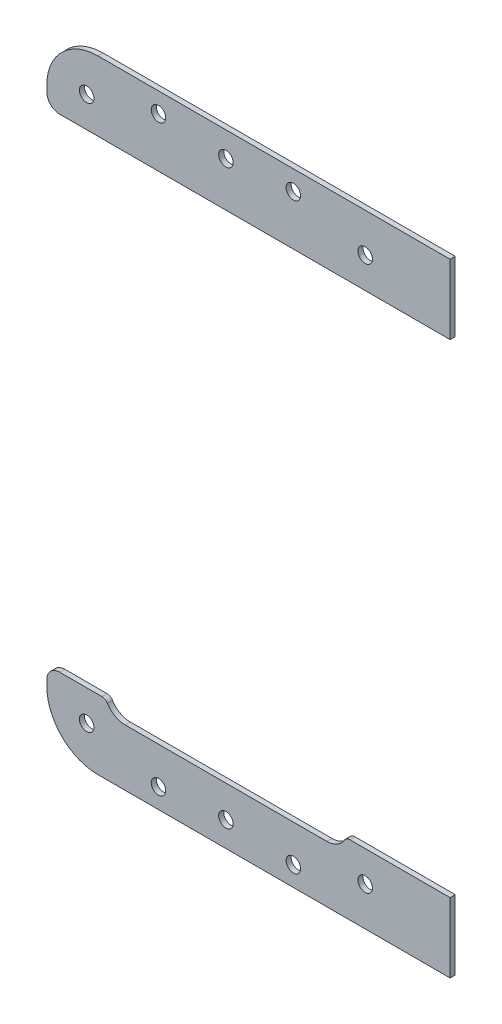
from build123d import *

# Parameters (mm, degrees)
SKETCH2_W                     = 111.125
SKETCH2_H                     = 193.04
BOSS_EXTRUDE1_DEPTH           = 1.5875
FILLET1_R                     = 15.875
SKETCH6_R                     = 2.4003
SKETCH6_R_2                   = 3
SKETCH6_R_3                   = 6.477
SKETCH6_R_4                   = 10.762
CUT_EXTRUDE1_DEPTH            = 212.192646736
SKETCH7_W                     = 13.97
SKETCH7_H                     = 193.04
BOSS_EXTRUDE2_DEPTH           = 1.5875
SKETCH8_W                     = 75.32443897
SKETCH8_H                     = 38.1
SKETCH8_R                     = 10.762
SKETCH8_R_2                   = 3
SKETCH8_H_2                   = 31.75
SKETCH8_H_3                   = 34.487219484
SKETCH8_R_3                   = 2.4003
SKETCH8_R_4                   = 6.477
SKETCH8_R_5                   = 8.9535
CUT_EXTRUDE2_DEPTH            = 1.5875
FILLET2_R                     = 9.525
FILLET3_R                     = 6.35
FILLET4_R                     = 9.525
SKETCH9_W                     = 125.095
SKETCH9_H                     = 149.86
CUT_EXTRUDE5_DEPTH            = 80
FILLET6_R                     = 4
FILLET8_R                     = 2
FILLET9_R                     = 2
FILLET10_R                    = 4
SKETCH4_W                     = 2.25
SKETCH4_H                     = 1.5875
M4_CLEARANCE_HOLE1_AT_2_COUNT = 2
M4_CLEARANCE_HOLE1_AT_2_PITCH = 43.406709572
M4_CLEARANCE_HOLE1_AT_3_COUNT = 2
M4_CLEARANCE_HOLE1_AT_3_PITCH = 86.3827405
M4_CLEARANCE_HOLE1_AT_4_COUNT = 2
M4_CLEARANCE_HOLE1_AT_4_PITCH = 189.737314909
M4_CLEARANCE_HOLE1_AT_5_COUNT = 2
M4_CLEARANCE_HOLE1_AT_5_PITCH = 178.553711266
M4_CLEARANCE_HOLE1_AT_6_COUNT = 2
M4_CLEARANCE_HOLE1_AT_6_PITCH = 168.9327405
M4_CLEARANCE_HOLE1_AT_7_COUNT = 2
M4_CLEARANCE_HOLE1_AT_7_PITCH = 23.050611575
M4_CLEARANCE_HOLE1_AT_8_COUNT = 2
M4_CLEARANCE_HOLE1_AT_8_PITCH = 186.221930585
SKETCH12_R                    = 2.25
CUT_EXTRUDE6_DEPTH            = 212.39048994


with BuildPart() as part:
    # Sketch2 → Boss-Extrude1 (new body)
    with BuildSketch(Plane.XY.offset(-401.504104662)):
        with Locations((-6.650833159, 105.295051609)):
            Rectangle(SKETCH2_W, SKETCH2_H)
        with BuildLine():
            ThreePointArc((40.429624387, 185.872334563), (40.429624387, 193.650509156), (32.651449794, 193.650509156))
            Line((32.651449794, 193.650509156), (29.670992248, 190.670051609))
            Line((29.670992248, 190.670051609), (-1.150833159, 190.670051609))
            Line((-1.150833159, 190.670051609), (-1.150833159, 194.079751609))
            ThreePointArc((-1.150833159, 194.079751609), (-6.650833159, 199.579751609), (-12.150833159, 194.079751609))
            Line((-12.150833159, 194.079751609), (-12.150833159, 190.670051609))
            Line((-12.150833159, 190.670051609), (-42.972658566, 190.670051609))
            Line((-42.972658566, 190.670051609), (-45.953116112, 193.650509156))
            ThreePointArc((-45.953116112, 193.650509156), (-53.731290705, 193.650509156), (-53.731290705, 185.872334563))
            Line((-53.731290705, 185.872334563), (-50.750833159, 182.891877016))
            Line((-50.750833159, 182.891877016), (-50.750833159, 138.989051609))
            Line((-50.750833159, 138.989051609), (-54.160533159, 138.989051609))
            ThreePointArc((-54.160533159, 138.989051609), (-59.660533159, 133.489051609), (-54.160533159, 127.989051609))
            Line((-54.160533159, 127.989051609), (-50.750833159, 127.989051609))
            Line((-50.750833159, 127.989051609), (-50.750833159, 82.601051609))
            Line((-50.750833159, 82.601051609), (-54.160533159, 82.601051609))
            ThreePointArc((-54.160533159, 82.601051609), (-59.660533159, 77.101051609), (-54.160533159, 71.601051609))
            Line((-54.160533159, 71.601051609), (-50.750833159, 71.601051609))
            Line((-50.750833159, 71.601051609), (-50.750833159, 27.698226203))
            Line((-50.750833159, 27.698226203), (-53.731290705, 24.717768656))
            ThreePointArc((-53.731290705, 24.717768656), (-53.731290705, 16.939594063), (-45.953116112, 16.939594063))
            Line((-45.953116112, 16.939594063), (-42.972658566, 19.920051609))
            Line((-42.972658566, 19.920051609), (-12.150833159, 19.920051609))
            Line((-12.150833159, 19.920051609), (-12.150833159, 16.510351609))
            ThreePointArc((-12.150833159, 16.510351609), (-6.650833159, 11.010351609), (-1.150833159, 16.510351609))
            Line((-1.150833159, 16.510351609), (-1.150833159, 19.920051609))
            Line((-1.150833159, 19.920051609), (29.670992248, 19.920051609))
            Line((29.670992248, 19.920051609), (32.651449794, 16.939594063))
            ThreePointArc((32.651449794, 16.939594063), (40.429624387, 16.939594063), (40.429624387, 24.717768656))
            Line((40.429624387, 24.717768656), (37.449166841, 27.698226203))
            Line((37.449166841, 27.698226203), (37.449166841, 71.601051609))
            Line((37.449166841, 71.601051609), (40.858866841, 71.601051609))
            ThreePointArc((40.858866841, 71.601051609), (46.358866841, 77.101051609), (40.858866841, 82.601051609))
            Line((40.858866841, 82.601051609), (37.449166841, 82.601051609))
            Line((37.449166841, 82.601051609), (37.449166841, 127.989051609))
            Line((37.449166841, 127.989051609), (40.858866841, 127.989051609))
            ThreePointArc((40.858866841, 127.989051609), (46.358866841, 133.489051609), (40.858866841, 138.989051609))
            Line((40.858866841, 138.989051609), (37.449166841, 138.989051609))
            Line((37.449166841, 138.989051609), (37.449166841, 182.891877016))
            Line((37.449166841, 182.891877016), (40.429624387, 185.872334563))
        make_face(mode=Mode.SUBTRACT)
        with BuildLine():
            Line((37.449166841, 182.891877016), (40.429624387, 185.872334563))
            ThreePointArc((40.429624387, 185.872334563), (40.429624387, 193.650509156), (32.651449794, 193.650509156))
            Line((32.651449794, 193.650509156), (29.670992248, 190.670051609))
            Line((29.670992248, 190.670051609), (-1.150833159, 190.670051609))
            Line((-1.150833159, 190.670051609), (-1.150833159, 194.079751609))
            ThreePointArc((-1.150833159, 194.079751609), (-6.650833159, 199.579751609), (-12.150833159, 194.079751609))
            Line((-12.150833159, 194.079751609), (-12.150833159, 190.670051609))
            Line((-12.150833159, 190.670051609), (-42.972658566, 190.670051609))
            Line((-42.972658566, 190.670051609), (-45.953116112, 193.650509156))
            ThreePointArc((-45.953116112, 193.650509156), (-53.731290705, 193.650509156), (-53.731290705, 185.872334563))
            Line((-53.731290705, 185.872334563), (-50.750833159, 182.891877016))
            Line((-50.750833159, 182.891877016), (-50.750833159, 138.989051609))
            Line((-50.750833159, 138.989051609), (-54.160533159, 138.989051609))
            ThreePointArc((-54.160533159, 138.989051609), (-59.660533159, 133.489051609), (-54.160533159, 127.989051609))
            Line((-54.160533159, 127.989051609), (-50.750833159, 127.989051609))
            Line((-50.750833159, 127.989051609), (-50.750833159, 82.601051609))
            Line((-50.750833159, 82.601051609), (-54.160533159, 82.601051609))
            ThreePointArc((-54.160533159, 82.601051609), (-59.660533159, 77.101051609), (-54.160533159, 71.601051609))
            Line((-54.160533159, 71.601051609), (-50.750833159, 71.601051609))
            Line((-50.750833159, 71.601051609), (-50.750833159, 27.698226203))
            Line((-50.750833159, 27.698226203), (-53.731290705, 24.717768656))
            ThreePointArc((-53.731290705, 24.717768656), (-53.731290705, 16.939594063), (-45.953116112, 16.939594063))
            Line((-45.953116112, 16.939594063), (-42.972658566, 19.920051609))
            Line((-42.972658566, 19.920051609), (-12.150833159, 19.920051609))
            Line((-12.150833159, 19.920051609), (-12.150833159, 16.510351609))
            ThreePointArc((-12.150833159, 16.510351609), (-6.650833159, 11.010351609), (-1.150833159, 16.510351609))
            Line((-1.150833159, 16.510351609), (-1.150833159, 19.920051609))
            Line((-1.150833159, 19.920051609), (29.670992248, 19.920051609))
            Line((29.670992248, 19.920051609), (32.651449794, 16.939594063))
            ThreePointArc((32.651449794, 16.939594063), (40.429624387, 16.939594063), (40.429624387, 24.717768656))
            Line((40.429624387, 24.717768656), (37.449166841, 27.698226203))
            Line((37.449166841, 27.698226203), (37.449166841, 71.601051609))
            Line((37.449166841, 71.601051609), (40.858866841, 71.601051609))
            ThreePointArc((40.858866841, 71.601051609), (46.358866841, 77.101051609), (40.858866841, 82.601051609))
            Line((40.858866841, 82.601051609), (37.449166841, 82.601051609))
            Line((37.449166841, 82.601051609), (37.449166841, 127.989051609))
            Line((37.449166841, 127.989051609), (40.858866841, 127.989051609))
            ThreePointArc((40.858866841, 127.989051609), (46.358866841, 133.489051609), (40.858866841, 138.989051609))
            Line((40.858866841, 138.989051609), (37.449166841, 138.989051609))
            Line((37.449166841, 138.989051609), (37.449166841, 182.891877016))
        make_face()
    extrude(amount=BOSS_EXTRUDE1_DEPTH)

    # Fillet1
    fillet1_edges = [part.edges().sort_by_distance(p)[0] for p in [
        (-62.213333159, 201.815051609, -400.710354662),
        (-62.213333159, 8.775051609, -400.710354662),
    ]]
    fillet(fillet1_edges, radius=FILLET1_R)

    # Sketch6 → Cut-Extrude1 (cut, through all)
    with BuildSketch(Plane.XY.offset(-399.916604662)):
        with Locations((-34.590833159, 43.382551609)):
            Circle(SKETCH6_R)
        with Locations((21.289166841, 43.382551609)):
            Circle(SKETCH6_R)
        with Locations((-20.884724927, 142.590766631)):
            Circle(SKETCH6_R_2)
        with Locations((7.583058609, 166.225175879)):
            Circle(SKETCH6_R_2)
        with Locations((3.509166841, 43.382551609)):
            Circle(SKETCH6_R_3)
        with Locations((-16.810833159, 43.382551609)):
            Circle(SKETCH6_R_3)
        with Locations((-33.320833159, 123.670051609)):
            Circle(SKETCH6_R_3)
        with Locations((-6.650833159, 154.407971255)):
            Circle(SKETCH6_R_4)
        with Locations((-6.650833159, 94.607131964)):
            Circle(SKETCH6_R_4)
    extrude(amount=-CUT_EXTRUDE1_DEPTH, mode=Mode.SUBTRACT)

    # Sketch7 → Boss-Extrude2 (add)
    with BuildSketch(Plane.XY.offset(-399.916604662)):
        with Locations((55.896666841, 105.295051609)):
            Rectangle(SKETCH7_W, SKETCH7_H)
    extrude(amount=-BOSS_EXTRUDE2_DEPTH)

    # Sketch8 → Cut-Extrude2 (cut)
    with BuildSketch(Plane.XY.offset(-399.916604662)):
        with Locations((-6.650833159, 154.407971255)):
            Rectangle(SKETCH8_W, SKETCH8_H)
        with Locations((-6.650833159, 154.407971255)):
            Circle(SKETCH8_R, mode=Mode.SUBTRACT)
        with Locations((7.583058609, 166.225175879)):
            Circle(SKETCH8_R_2, mode=Mode.SUBTRACT)
        with Locations((-20.884724927, 142.590766631)):
            Circle(SKETCH8_R_2, mode=Mode.SUBTRACT)
        with Locations((-6.650833159, 94.607131964)):
            Rectangle(SKETCH8_W, SKETCH8_H_2)
        with Locations((-6.650833159, 94.607131964)):
            Circle(SKETCH8_R, mode=Mode.SUBTRACT)
        with Locations((-6.650833159, 43.601441867)):
            Rectangle(SKETCH8_W, SKETCH8_H_3)
        with Locations((-34.590833159, 43.382551609)):
            Circle(SKETCH8_R_3, mode=Mode.SUBTRACT)
        with Locations((-16.810833159, 43.382551609)):
            Circle(SKETCH8_R_4, mode=Mode.SUBTRACT)
        with Locations((3.509166841, 43.382551609)):
            Circle(SKETCH8_R_4, mode=Mode.SUBTRACT)
        with Locations((21.289166841, 43.382551609)):
            Circle(SKETCH8_R_3, mode=Mode.SUBTRACT)
        with Locations((-33.320833159, 123.670051609)):
            Circle(SKETCH8_R_5)
        with Locations((-33.320833159, 123.670051609)):
            Circle(SKETCH8_R_4, mode=Mode.SUBTRACT)
    extrude(amount=-CUT_EXTRUDE2_DEPTH, mode=Mode.SUBTRACT)

    # Fillet2
    fillet2_edges = [part.edges().sort_by_distance(p)[0] for p in [
        (31.011386326, 135.357971255, -400.710354662),
        (-44.313052644, 135.357971255, -400.710354662),
        (-44.313052644, 173.457971255, -400.710354662),
        (31.011386326, 173.457971255, -400.710354662),
    ]]
    fillet(fillet2_edges, radius=FILLET2_R)

    # Fillet3
    fillet3_edges = [part.edges().sort_by_distance(p)[0] for p in [
        (-44.313052644, 60.845051609, -400.710354662),
        (31.011386326, 60.845051609, -400.710354662),
        (31.011386326, 26.357832125, -400.710354662),
        (-44.313052644, 26.357832125, -400.710354662),
    ]]
    fillet(fillet3_edges, radius=FILLET3_R)

    # Fillet4
    fillet4_edges = [part.edges().sort_by_distance(p)[0] for p in [
        (31.011386326, 110.482131964, -400.710354662),
        (31.011386326, 78.732131964, -400.710354662),
        (-44.313052644, 78.732131964, -400.710354662),
        (-44.313052644, 110.482131964, -400.710354662),
    ]]
    fillet(fillet4_edges, radius=FILLET4_R)

    # Sketch9 → Cut-Extrude5 (cut)
    with BuildSketch(Plane.XY.offset(-399.916604662)):
        with Locations((0.334166841, 105.295051609)):
            Rectangle(SKETCH9_W, SKETCH9_H)
    extrude(amount=-CUT_EXTRUDE5_DEPTH, mode=Mode.SUBTRACT)


with BuildPart() as cut_extrude5_piece_1:
    # of the separate pieces the step leaves, piece 1, a body of its own (cut_extrude5_pieces)
    add(part.part.solids().sort_by_distance((62.881666841, 201.815051609, -401.504104662))[0])

    # Fillet10
    fillet10_edges = [cut_extrude5_piece_1.edges().sort_by_distance(p)[0] for p in [
        (-62.213333159, 180.225051609, -400.710354662),
    ]]
    fillet(fillet10_edges, radius=FILLET10_R)

    # Sketch4 → M4 Clearance Hole1 (revolve, cut)
    with BuildSketch(Plane(origin=(36.540537091, 189.761421859, -399.916604662), x_dir=(0, -1, 0), z_dir=(1, 0, 0))):
        with Locations((1.125, 0.79375)):
            Rectangle(SKETCH4_W, SKETCH4_H)
    m4_clearance_hole1 = revolve(axis=Axis((36.540537091, 189.761421859, -393.566604662), (0, 0, -1)), mode=Mode.SUBTRACT)

    # M4 Clearance Hole1 at 2: M4 Clearance Hole1 ×2
    with Locations(*[Vector(-0.9950390314183887, 0.09948530521617187, 0) * (i * M4_CLEARANCE_HOLE1_AT_2_PITCH) for i in range(1, M4_CLEARANCE_HOLE1_AT_2_COUNT)]):
        add(m4_clearance_hole1, mode=Mode.SUBTRACT)

    # M4 Clearance Hole1 at 3: M4 Clearance Hole1 ×2
    with Locations(*[(-i * M4_CLEARANCE_HOLE1_AT_3_PITCH, 0, 0) for i in range(1, M4_CLEARANCE_HOLE1_AT_3_COUNT)]):
        add(m4_clearance_hole1, mode=Mode.SUBTRACT)

    # M4 Clearance Hole1 at 7: M4 Clearance Hole1 ×2
    with Locations(*[Vector(-0.9665885641891935, 0.25633288430997997, 0) * (i * M4_CLEARANCE_HOLE1_AT_7_PITCH) for i in range(1, M4_CLEARANCE_HOLE1_AT_7_COUNT)]):
        add(m4_clearance_hole1, mode=Mode.SUBTRACT)


with BuildPart() as cut_extrude5_piece_2:
    # of the separate pieces the step leaves, piece 2, a body of its own (cut_extrude5_pieces)
    add(part.part.solids().sort_by_distance((30.563409662, 30.365051609, -401.504104662))[0])

    # Fillet6
    fillet6_edges = [cut_extrude5_piece_2.edges().sort_by_distance(p)[0] for p in [
        (-62.213333159, 30.365051609, -400.710354662),
    ]]
    fillet(fillet6_edges, radius=FILLET6_R)

    # Fillet8
    fillet8_edges = [cut_extrude5_piece_2.edges().sort_by_distance(p)[0] for p in [
        (-43.86507598, 30.365051609, -400.710354662),
    ]]
    fillet(fillet8_edges, radius=FILLET8_R)

    # Fillet9
    fillet9_edges = [cut_extrude5_piece_2.edges().sort_by_distance(p)[0] for p in [
        (30.563409662, 30.365051609, -400.710354662),
    ]]
    fillet(fillet9_edges, radius=FILLET9_R)

    # M4 Clearance Hole1 at 4: M4 Clearance Hole1 ×2
    with Locations(*[Vector(-0.45527544511186635, -0.890350643891603, 0) * (i * M4_CLEARANCE_HOLE1_AT_4_PITCH) for i in range(1, M4_CLEARANCE_HOLE1_AT_4_COUNT)]):
        add(m4_clearance_hole1, mode=Mode.SUBTRACT)

    # M4 Clearance Hole1 at 5: M4 Clearance Hole1 ×2
    with Locations(*[Vector(-0.24189567354056962, -0.970302263793275, 0) * (i * M4_CLEARANCE_HOLE1_AT_5_PITCH) for i in range(1, M4_CLEARANCE_HOLE1_AT_5_COUNT)]):
        add(m4_clearance_hole1, mode=Mode.SUBTRACT)

    # M4 Clearance Hole1 at 6: M4 Clearance Hole1 ×2
    with Locations(*[(0, -i * M4_CLEARANCE_HOLE1_AT_6_PITCH, 0) for i in range(1, M4_CLEARANCE_HOLE1_AT_6_COUNT)]):
        add(m4_clearance_hole1, mode=Mode.SUBTRACT)

    # M4 Clearance Hole1 at 8: M4 Clearance Hole1 ×2
    with Locations(*[Vector(-0.34422520887864616, -0.9388871101322313, 0) * (i * M4_CLEARANCE_HOLE1_AT_8_PITCH) for i in range(1, M4_CLEARANCE_HOLE1_AT_8_COUNT)]):
        add(m4_clearance_hole1, mode=Mode.SUBTRACT)


with BuildPart() as cut_extrude6_tool:
    # Sketch12 → Cut-Extrude6 (new, through all)
    with BuildSketch(Plane.XY.offset(-399.916604662)):
        with Locations((14.260079544, 195.670051609)):
            Circle(SKETCH12_R)
        with Locations((-27.561745863, 14.920051609)):
            Circle(SKETCH12_R)
        with Locations(Location((14.260079544, 14.920051609, 0), (0, 0, 180))):
            Circle(SKETCH12_R)
        with Locations(Location((-27.561745863, 195.670051609, 0), (0, 0, 180))):
            Circle(SKETCH12_R)
    extrude(amount=-CUT_EXTRUDE6_DEPTH)


with BuildPart() as cut_extrude5_piece_1_1:
    add(cut_extrude5_piece_1.part)

    # Cut-Extrude6: cut by cut_extrude6_tool
    add(cut_extrude6_tool.part, mode=Mode.SUBTRACT)


with BuildPart() as cut_extrude5_piece_2_1:
    add(cut_extrude5_piece_2.part)

    # Cut-Extrude6: cut by cut_extrude6_tool
    add(cut_extrude6_tool.part, mode=Mode.SUBTRACT)


solid = Compound([cut_extrude5_piece_1_1.part, cut_extrude5_piece_2_1.part])
